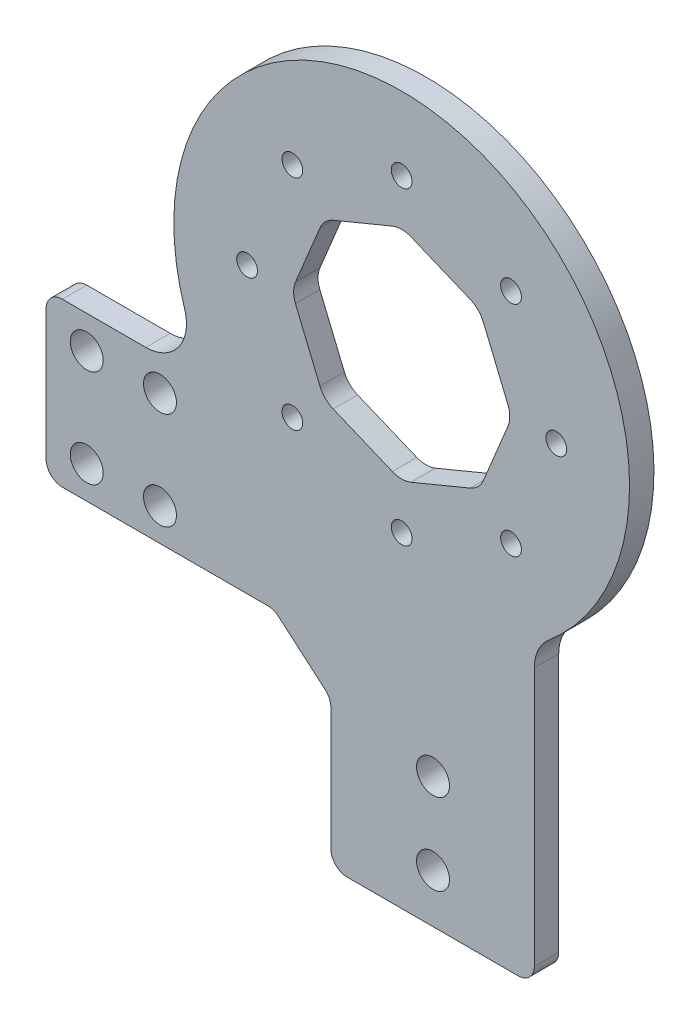
from build123d import *

# Parameters (mm, degrees)
EXTRUDE_1_DEPTH          = 1.5
SKETCH_2_R               = 28
EXTRUDE_2_DEPTH          = 3
FILLET_1_R               = 2
SKETCH_3_R               = 1.275
CUT_EXTRUDE_1_DEPTH      = 4
SKETCH_4_R               = 2.025
CUT_EXTRUDE_2_DEPTH      = 4
SKETCH_5_W               = 25
SKETCH_5_H               = 6
CUT_EXTRUDE_3_DEPTH      = 4
FILLET_2_R               = 2
SKETCH_6_R               = 2.025
CUT_EXTRUDE_4_DEPTH      = 10
FILLET_3_R               = 5
SKETCH_7_R               = 2.025
CUT_EXTRUDE_5_DEPTH      = 1
CUT_EXTRUDE_5_DEPTH_BACK = 4
CUT_EXTRUDE_6_DEPTH      = 10
FILLET_4_R               = 3


with BuildPart() as part:
    # 草图1 → 凸台-拉伸1 (new body, symmetric)
    with BuildSketch(Plane.XY):
        Polygon((0, 0), (0, 24), (-7, 30), (-35, 30), (-35, 50), (25, 50), (25, 0), align=None)
    extrude(amount=EXTRUDE_1_DEPTH, both=True)

    # 草图2 → 凸台-拉伸2 (add)
    with BuildSketch(Plane.XY.offset(1.5)):
        with Locations((8.7, 65)):
            Circle(SKETCH_2_R)
    extrude(amount=-EXTRUDE_2_DEPTH)

    # 圆角1
    fillet_1_edges = [part.edges().sort_by_distance(p)[0] for p in [
        (0, 0, 0),
        (0, 24, 0),
        (-7, 30, 0),
        (-35, 30, 0),
        (-35, 50, 0),
        (25, 0, 0),
    ]]
    fillet(fillet_1_edges, radius=FILLET_1_R)

    # 草图3 → 切除-拉伸1 (cut, through all)
    with BuildSketch(Plane.XY.offset(1.5)):
        with Locations((22.135028843, 78.435028843)):
            Circle(SKETCH_3_R)
        with Locations((27.7, 65)):
            Circle(SKETCH_3_R)
        with Locations((22.135028843, 51.564971157)):
            Circle(SKETCH_3_R)
        with Locations((8.7, 46)):
            Circle(SKETCH_3_R)
        with Locations((-4.735028843, 51.564971157)):
            Circle(SKETCH_3_R)
        with Locations((-10.3, 65)):
            Circle(SKETCH_3_R)
        with Locations((-4.735028843, 78.435028843)):
            Circle(SKETCH_3_R)
        with Locations((8.7, 84)):
            Circle(SKETCH_3_R)
    extrude(amount=-CUT_EXTRUDE_1_DEPTH, mode=Mode.SUBTRACT)

    # 草图4 → 切除-拉伸2 (cut, through all)
    with BuildSketch(Plane.XY.offset(1.5)):
        with Locations((12.55, 22)):
            Circle(SKETCH_4_R)
        with Locations((12.55, 12)):
            Circle(SKETCH_4_R)
    extrude(amount=-CUT_EXTRUDE_2_DEPTH, mode=Mode.SUBTRACT)

    # 草图5 → 切除-拉伸3 (cut, through all)
    with BuildSketch(Plane.XY.offset(1.5)):
        with Locations((12.5, 3)):
            Rectangle(SKETCH_5_W, SKETCH_5_H)
    extrude(amount=-CUT_EXTRUDE_3_DEPTH, mode=Mode.SUBTRACT)

    # 圆角2
    fillet_2_edges = [part.edges().sort_by_distance(p)[0] for p in [
        (0, 6, 0),
        (25, 6, 0),
    ]]
    fillet(fillet_2_edges, radius=FILLET_2_R)

    # 草图6 → 切除-拉伸4 (cut)
    with BuildSketch(Plane.XY.offset(1.5)):
        with Locations((-30, 46)):
            Circle(SKETCH_6_R)
        with Locations((-30, 34)):
            Circle(SKETCH_6_R)
    extrude(amount=-CUT_EXTRUDE_4_DEPTH, mode=Mode.SUBTRACT)

    # 圆角3
    fillet_3_edges = [part.edges().sort_by_distance(p)[0] for p in [
        (25, 42.233577356, 0),
        (-14.943180835, 50, 0),
    ]]
    fillet(fillet_3_edges, radius=FILLET_3_R)

    # 草图7 → 切除-拉伸5 (cut, two sides)
    with BuildSketch(Plane.XY.offset(1.5)) as cut_extrude_5_sk:
        with Locations((-21, 46)):
            Circle(SKETCH_7_R)
        with Locations((-21, 34)):
            Circle(SKETCH_7_R)
    extrude(amount=CUT_EXTRUDE_5_DEPTH, mode=Mode.SUBTRACT)
    extrude(cut_extrude_5_sk.sketch, amount=-CUT_EXTRUDE_5_DEPTH_BACK, mode=Mode.SUBTRACT)

    # 草图8 → 切除-拉伸6 (cut)
    with BuildSketch(Plane.XY.offset(1.5)):
        Polygon((8.7, 78.529902504), (-0.867085809, 74.567085809), (-4.829902504, 65), (-0.867085809, 55.432914191), (8.7, 51.470097496), (18.267085809, 55.432914191), (22.229902504, 65), (18.267085809, 74.567085809), align=None)
    extrude(amount=-CUT_EXTRUDE_6_DEPTH, mode=Mode.SUBTRACT)

    # 圆角4
    fillet_4_edges = [part.edges().sort_by_distance(p)[0] for p in [
        (8.7, 78.529902504, 0),
        (18.267085809, 74.567085809, 0),
        (22.229902504, 65, 0),
        (18.267085809, 55.432914191, 0),
        (8.7, 51.470097496, 0),
        (-0.867085809, 55.432914191, 0),
        (-4.829902504, 65, 0),
        (-0.867085809, 74.567085809, 0),
    ]]
    fillet(fillet_4_edges, radius=FILLET_4_R)


solid = part.part
